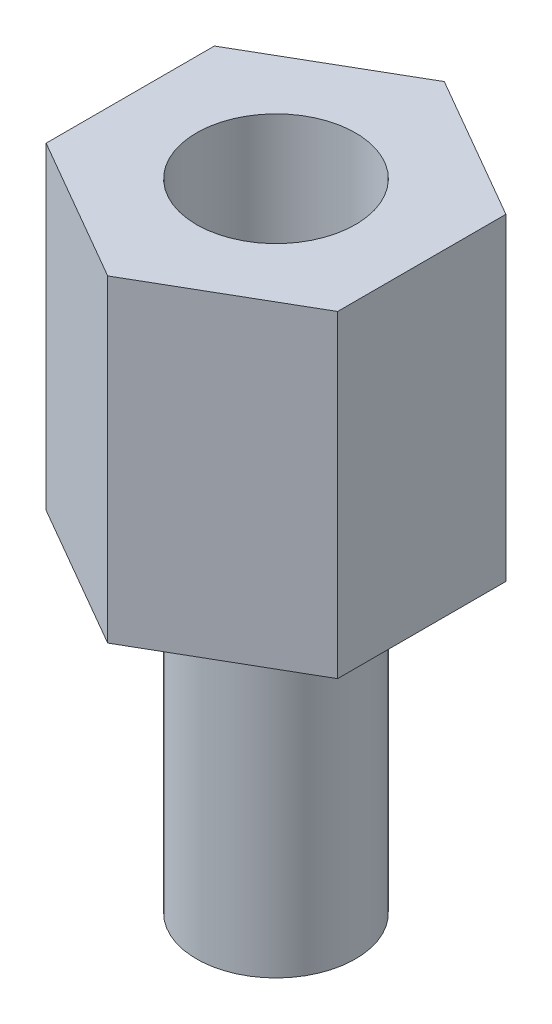
from build123d import *

# Parameters (mm, degrees)
SALIENTE_EXTRUIR1_DEPTH = 6
CROQUIS2_R              = 1.5
SALIENTE_EXTRUIR2_DEPTH = 6
CROQUIS3_R              = 1.5
CORTAR_EXTRUIR1_DEPTH   = 5.5


with BuildPart() as part:
    # Croquis1 → Saliente-Extruir1 (new body)
    with BuildSketch(Plane(origin=(0, 0, 0), x_dir=(1, 0, 0), z_dir=(0, 1, 0))):
        Polygon((0, 3.175426481), (-2.75, 1.58771324), (-2.75, -1.58771324), (0, -3.175426481), (2.75, -1.58771324), (2.75, 1.58771324), align=None)
    extrude(amount=SALIENTE_EXTRUIR1_DEPTH)

    # Croquis2 → Saliente-Extruir2 (add)
    with BuildSketch(Plane.XZ):
        Circle(CROQUIS2_R)
    extrude(amount=SALIENTE_EXTRUIR2_DEPTH)

    # Croquis3 → Cortar-Extruir1 (cut)
    with BuildSketch(Plane(origin=(0, 6, 0), x_dir=(1, 0, 0), z_dir=(0, 1, 0))):
        Circle(CROQUIS3_R)
    extrude(amount=-CORTAR_EXTRUIR1_DEPTH, mode=Mode.SUBTRACT)


solid = part.part
